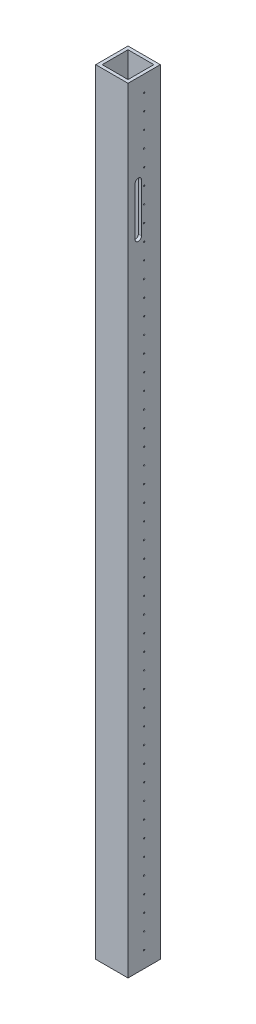
from build123d import *

# Parameters (mm, degrees)
SKETCH1_W           = 25.4
SKETCH1_H           = 25.4
SKETCH1_W_2         = 20.32
SKETCH1_H_2         = 20.32
BOSS_EXTRUDE1_DEPTH = 609.6
SKETCH2_R           = 0.5
CUT_EXTRUDE2_DEPTH  = 62.23
SKETCH4_W           = 2.54
SKETCH4_H           = 38.1
CUT_EXTRUDE4_DEPTH  = 111.76


with BuildPart() as part:
    # Sketch1 → Boss-Extrude1 (new body)
    with BuildSketch(Plane(origin=(0, 0, 0), x_dir=(1, 0, 0), z_dir=(0, 1, 0))):
        with Locations((10.16, 10.16)):
            Rectangle(SKETCH1_W, SKETCH1_H)
        with Locations((10.16, 10.16)):
            Rectangle(SKETCH1_W_2, SKETCH1_H_2, mode=Mode.SUBTRACT)
    extrude(amount=BOSS_EXTRUDE1_DEPTH)

    # Sketch2 → Cut-Extrude2 (cut)
    with BuildSketch(Plane(origin=(22.86, 0, 0), x_dir=(0, 0, -1), z_dir=(1, 0, 0))):
        with Locations((10.16, 596.9)):
            Circle(SKETCH2_R)
        with Locations((10.16, 584.2)):
            Circle(SKETCH2_R)
        with Locations((10.16, 571.5)):
            Circle(SKETCH2_R)
        with Locations((10.16, 558.8)):
            Circle(SKETCH2_R)
        with Locations((10.16, 546.1)):
            Circle(SKETCH2_R)
        with Locations((10.16, 533.4)):
            Circle(SKETCH2_R)
        with Locations((10.16, 520.7)):
            Circle(SKETCH2_R)
        with Locations((10.16, 508)):
            Circle(SKETCH2_R)
        with Locations((10.16, 495.3)):
            Circle(SKETCH2_R)
        with Locations((10.16, 482.6)):
            Circle(SKETCH2_R)
        with Locations((10.16, 469.9)):
            Circle(SKETCH2_R)
        with Locations((10.16, 457.2)):
            Circle(SKETCH2_R)
        with Locations((10.16, 444.5)):
            Circle(SKETCH2_R)
        with Locations((10.16, 431.8)):
            Circle(SKETCH2_R)
        with Locations((10.16, 419.1)):
            Circle(SKETCH2_R)
        with Locations((10.16, 406.4)):
            Circle(SKETCH2_R)
        with Locations((10.16, 393.7)):
            Circle(SKETCH2_R)
        with Locations((10.16, 381)):
            Circle(SKETCH2_R)
        with Locations((10.16, 368.3)):
            Circle(SKETCH2_R)
        with Locations((10.16, 355.6)):
            Circle(SKETCH2_R)
        with Locations((10.16, 342.9)):
            Circle(SKETCH2_R)
        with Locations((10.16, 330.2)):
            Circle(SKETCH2_R)
        with Locations((10.16, 317.5)):
            Circle(SKETCH2_R)
        with Locations((10.16, 304.8)):
            Circle(SKETCH2_R)
        with Locations((10.16, 292.1)):
            Circle(SKETCH2_R)
        with Locations((10.16, 279.4)):
            Circle(SKETCH2_R)
        with Locations((10.16, 266.7)):
            Circle(SKETCH2_R)
        with Locations((10.16, 254)):
            Circle(SKETCH2_R)
        with Locations((10.16, 241.3)):
            Circle(SKETCH2_R)
        with Locations((10.16, 228.6)):
            Circle(SKETCH2_R)
        with Locations((10.16, 215.9)):
            Circle(SKETCH2_R)
        with Locations((10.16, 203.2)):
            Circle(SKETCH2_R)
        with Locations((10.16, 190.5)):
            Circle(SKETCH2_R)
        with Locations((10.16, 177.8)):
            Circle(SKETCH2_R)
        with Locations((10.16, 165.1)):
            Circle(SKETCH2_R)
        with Locations((10.16, 152.4)):
            Circle(SKETCH2_R)
        with Locations((10.16, 139.7)):
            Circle(SKETCH2_R)
        with Locations((10.16, 127)):
            Circle(SKETCH2_R)
        with Locations((10.16, 114.3)):
            Circle(SKETCH2_R)
        with Locations((10.16, 101.6)):
            Circle(SKETCH2_R)
        with Locations((10.16, 88.9)):
            Circle(SKETCH2_R)
        with Locations((10.16, 76.2)):
            Circle(SKETCH2_R)
        with Locations((10.16, 63.5)):
            Circle(SKETCH2_R)
        with Locations((10.16, 50.8)):
            Circle(SKETCH2_R)
        with Locations((10.16, 38.1)):
            Circle(SKETCH2_R)
        with Locations((10.16, 25.4)):
            Circle(SKETCH2_R)
        with Locations((10.16, 12.7)):
            Circle(SKETCH2_R)
    extrude(amount=-CUT_EXTRUDE2_DEPTH, mode=Mode.SUBTRACT)

    # Sketch4 → Cut-Extrude4 (cut)
    with BuildSketch(Plane(origin=(22.86, 0, 0), x_dir=(0, 0, -1), z_dir=(1, 0, 0))):
        with BuildLine():
            Line((5.588, 538.48), (8.128, 538.48))
            ThreePointArc((8.128, 538.48), (7.384051224, 540.276051224), (5.588, 541.02))
            Line((5.588, 541.02), (5.588, 538.48))
        make_face()
        with BuildLine():
            Line((3.048, 538.48), (5.588, 538.48))
            Line((5.588, 538.48), (5.588, 541.02))
            ThreePointArc((5.588, 541.02), (3.791948776, 540.276051224), (3.048, 538.48))
        make_face()
        with Locations((4.318, 519.43)):
            Rectangle(SKETCH4_W, SKETCH4_H)
        with BuildLine():
            Line((8.128, 500.38), (8.128, 538.48))
            Line((8.128, 538.48), (5.588, 538.48))
            Line((5.588, 538.48), (5.588, 500.38))
            Line((5.588, 500.38), (3.048, 500.38))
            ThreePointArc((3.048, 500.38), (5.588, 497.84), (8.128, 500.38))
        make_face()
    extrude(amount=-CUT_EXTRUDE4_DEPTH, mode=Mode.SUBTRACT)


solid = part.part
